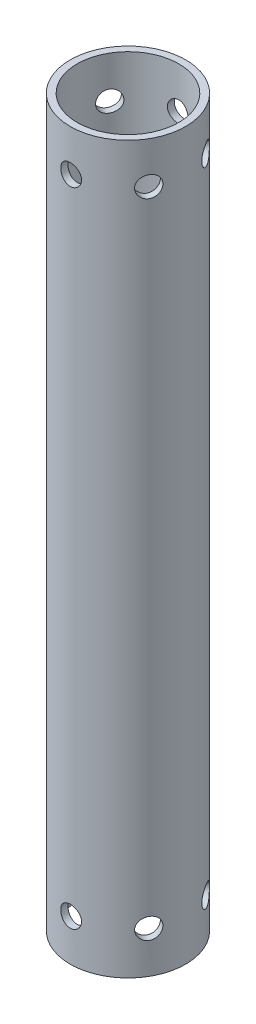
from build123d import *

# Parameters (mm, degrees)
SKETCH1_R                           = 39.6875
SKETCH1_R_2                         = 34.925
BOSS_EXTRUDE1_DEPTH                 = 498.602
F_9_16_0_5625_DIAMETER_HOLE1_REACH  = 508.438
F_9_16_0_5625_DIAMETER_HOLE1_BORE_R = 7.14375
CIRPATTERN1_COUNT                   = 6


with BuildPart() as part:
    # Sketch1 → Boss-Extrude1 (new body)
    with BuildSketch(Plane(origin=(0, 0, 0), x_dir=(1, 0, 0), z_dir=(0, 1, 0))):
        with Locations(Location((0, 0, 0), (0, 0, 270))):
            Circle(SKETCH1_R)
        with Locations(Location((0, 0, 0), (0, 0, 270))):
            Circle(SKETCH1_R_2, mode=Mode.SUBTRACT)
    extrude(amount=BOSS_EXTRUDE1_DEPTH)

    # 9/16 (0.5625) Diameter Hole1 bore → 9/16 (0.5625) Diameter Hole1 (cut, up to next)
    with BuildSketch(Plane.XY.offset(39.6875), mode=Mode.PRIVATE) as f_9_16_0_5625_diameter_hole1_sk1:
        with Locations((0, 470.027)):
            Circle(F_9_16_0_5625_DIAMETER_HOLE1_BORE_R)
    f_9_16_0_5625_diameter_hole1_tool1 = extrude(f_9_16_0_5625_diameter_hole1_sk1.sketch, amount=-F_9_16_0_5625_DIAMETER_HOLE1_REACH, mode=Mode.PRIVATE) & part.part
    # 9/16 (0.5625) Diameter Hole1 bore → 9/16 (0.5625) Diameter Hole1 (cut, up to next)
    with BuildSketch(Plane.XY.offset(39.6875), mode=Mode.PRIVATE) as f_9_16_0_5625_diameter_hole1_sk2:
        with Locations((0, 28.575)):
            Circle(F_9_16_0_5625_DIAMETER_HOLE1_BORE_R)
    f_9_16_0_5625_diameter_hole1_tool2 = extrude(f_9_16_0_5625_diameter_hole1_sk2.sketch, amount=-F_9_16_0_5625_DIAMETER_HOLE1_REACH, mode=Mode.PRIVATE) & part.part
    f_9_16_0_5625_diameter_hole1_1 = f_9_16_0_5625_diameter_hole1_tool1.solids().sort_by_distance((0, 470.027, 39.6875))[0]
    add(f_9_16_0_5625_diameter_hole1_1, mode=Mode.SUBTRACT)
    f_9_16_0_5625_diameter_hole1_2 = f_9_16_0_5625_diameter_hole1_tool2.solids().sort_by_distance((0, 28.575, 39.6875))[0]
    add(f_9_16_0_5625_diameter_hole1_2, mode=Mode.SUBTRACT)
    f_9_16_0_5625_diameter_hole1 = f_9_16_0_5625_diameter_hole1_1 + f_9_16_0_5625_diameter_hole1_2  # 9/16 (0.5625) Diameter Hole1 as one shape, for the pattern or mirror that repeats it

    # CirPattern1: 9/16 (0.5625) Diameter Hole1 ×6 about axis
    cirpattern1_axis = Axis((0, 498.602, 0), (0, -1, 0))
    for i in range(1, CIRPATTERN1_COUNT):
        add(f_9_16_0_5625_diameter_hole1.rotate(cirpattern1_axis, i * 360 / CIRPATTERN1_COUNT), mode=Mode.SUBTRACT)


solid = part.part
